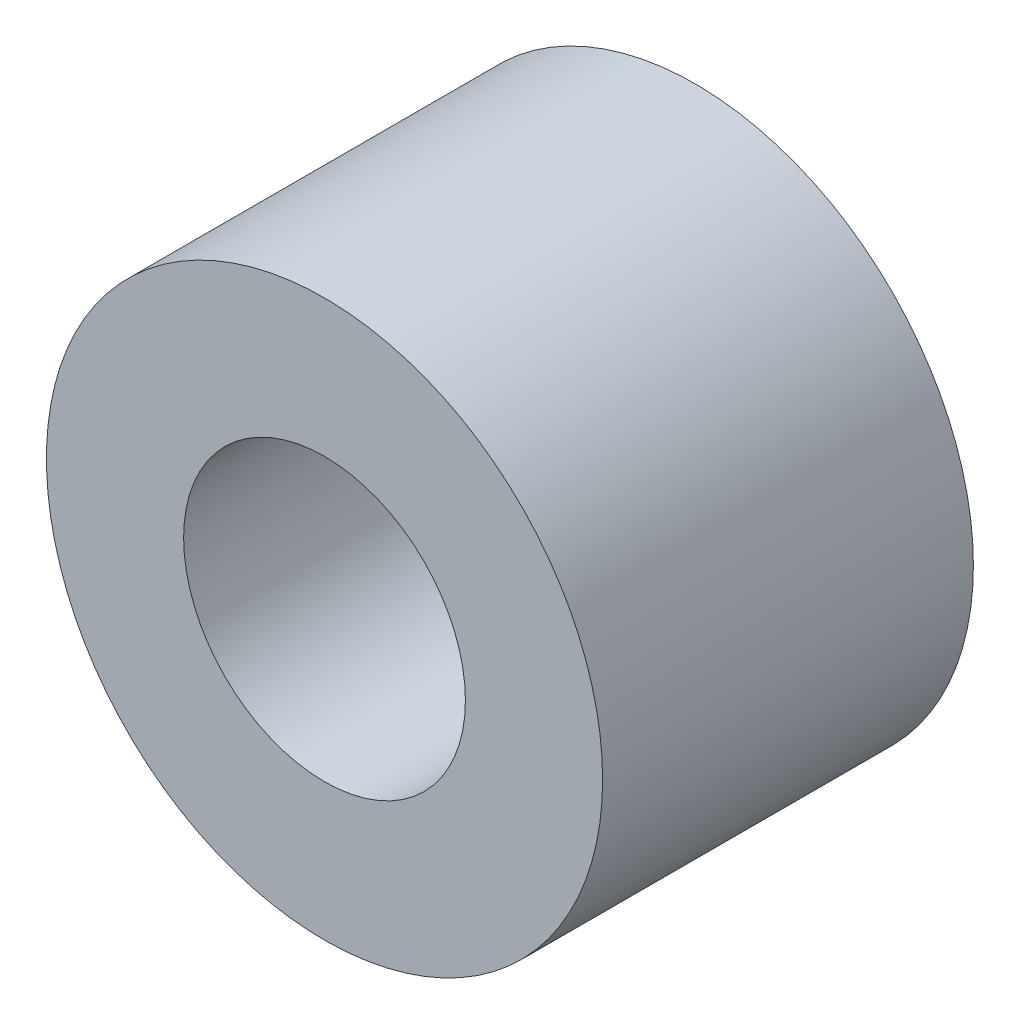
from build123d import *

# Parameters (mm, degrees)
SKETCH1_R           = 9.525
SKETCH1_R_2         = 4.826
EXTRUDE1_DEPTH      = 6.35
EXTRUDE1_DEPTH_BACK = 6.35


with BuildPart() as part:
    # Sketch1 → Extrude1 (new body, two sides)
    with BuildSketch(Plane.XY) as extrude1_sk:
        Circle(SKETCH1_R)
        Circle(SKETCH1_R_2, mode=Mode.SUBTRACT)
    extrude(amount=EXTRUDE1_DEPTH)
    extrude(extrude1_sk.sketch, amount=-EXTRUDE1_DEPTH_BACK)


solid = part.part
